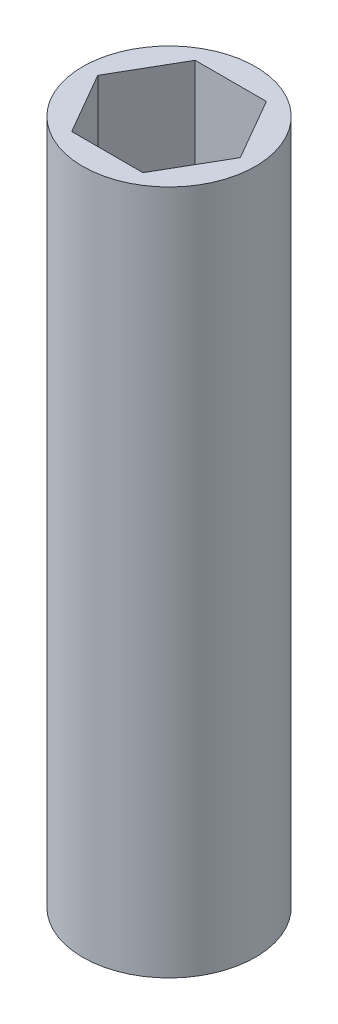
from build123d import *

# Parameters (mm, degrees)
SKETCH1_R           = 7.112
BOSS_EXTRUDE1_DEPTH = 56.388


with BuildPart() as part:
    # Sketch1 → Boss-Extrude1 (new body)
    with BuildSketch(Plane(origin=(0, 0, 0), x_dir=(1, 0, 0), z_dir=(0, 1, 0))):
        Circle(SKETCH1_R)
        Polygon((2.932939367, -5.08), (5.865878735, 0), (2.932939367, 5.08), (-2.932939367, 5.08), (-5.865878735, 0), (-2.932939367, -5.08), align=None, mode=Mode.SUBTRACT)
    extrude(amount=BOSS_EXTRUDE1_DEPTH)


solid = part.part
